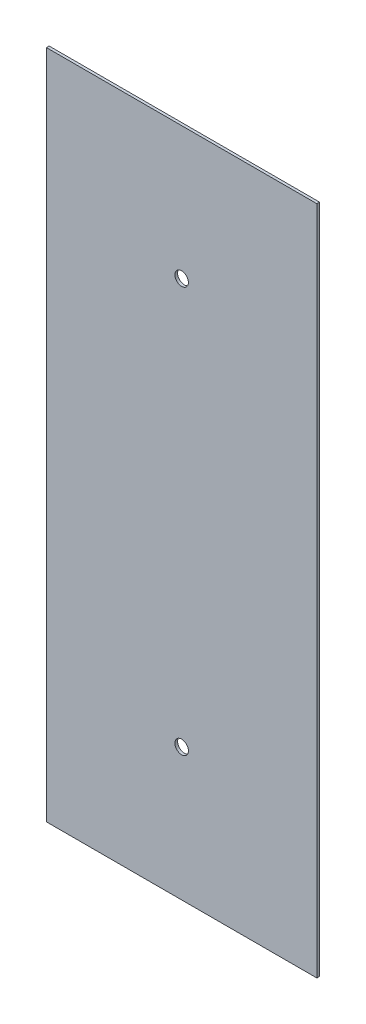
from build123d import *

# Parameters (mm, degrees)
SKETCH1_W           = 200
SKETCH1_H           = 496
SKETCH1_R           = 5
BOSS_EXTRUDE1_DEPTH = 2


with BuildPart() as part:
    # Sketch1 → Boss-Extrude1 (new body)
    with BuildSketch(Plane.XY):
        Rectangle(SKETCH1_W, SKETCH1_H)
        with Locations((0, 150)):
            Circle(SKETCH1_R, mode=Mode.SUBTRACT)
        with Locations((0, -150)):
            Circle(SKETCH1_R, mode=Mode.SUBTRACT)
    extrude(amount=BOSS_EXTRUDE1_DEPTH)


solid = part.part
